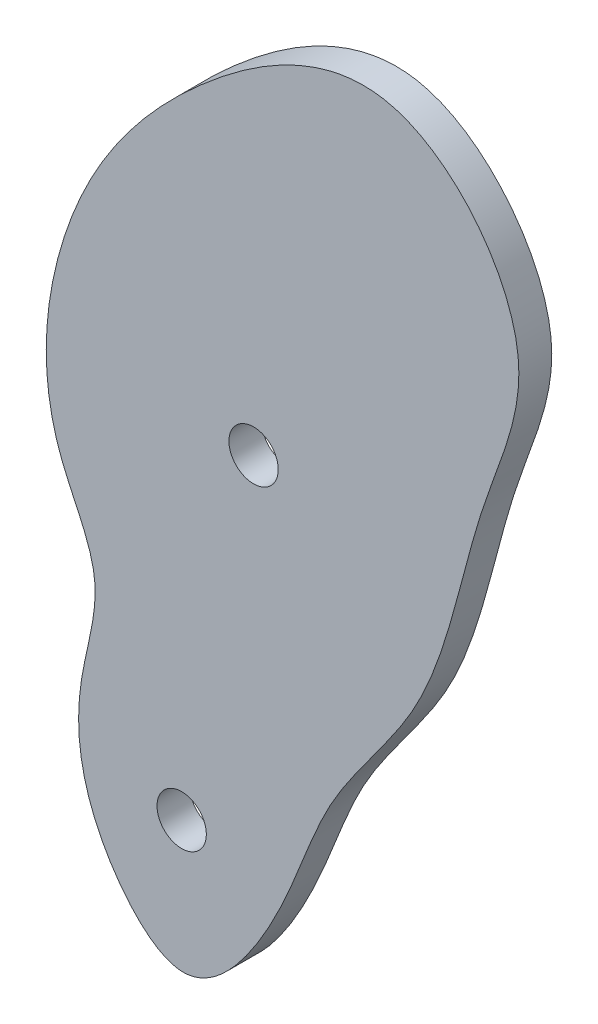
from build123d import *

# Parameters (mm, degrees)
SKETCH1_R           = 2.38125
BOSS_EXTRUDE1_DEPTH = 3.175


with BuildPart() as part:
    # Sketch1 → Boss-Extrude1 (new body)
    with BuildSketch(Plane.XY):
        with BuildLine():
            add(Edge.make_bspline(
                [(283.05514499, 237.827067537), (283.547387232, 240.919117609), (285.75244035, 247.114148413), (278.558893423, 258.013088166), (280.249302446, 276.578122362), (292.053750531, 293.066129838), (313.314576683, 306.294257446), (328.645034259, 287.265736466), (320.196895259, 269.71363934), (318.003950983, 252.959767112), (305.974927076, 239.730178242), (303.03774951, 227.739852532), (293.420219347, 214.663935577), (283.394591114, 225.72436445), (282.331103987, 233.278959214), (283.05514499, 237.827067537)],
                knots=[0, 0, 0, 0, 0.04653281, 0.091899368, 0.184135114, 0.305130434, 0.401870509, 0.499210838, 0.570860414, 0.681213866, 0.750347859, 0.825644279, 0.883835322, 0.931554711, 1, 1, 1, 1], degree=3))
        make_face()
        with Locations((299.663894036, 264.84727121)):
            Circle(SKETCH1_R, mode=Mode.SUBTRACT)
        with Locations((292.722924285, 230.886097787)):
            Circle(SKETCH1_R, mode=Mode.SUBTRACT)
    extrude(amount=BOSS_EXTRUDE1_DEPTH)


solid = part.part
